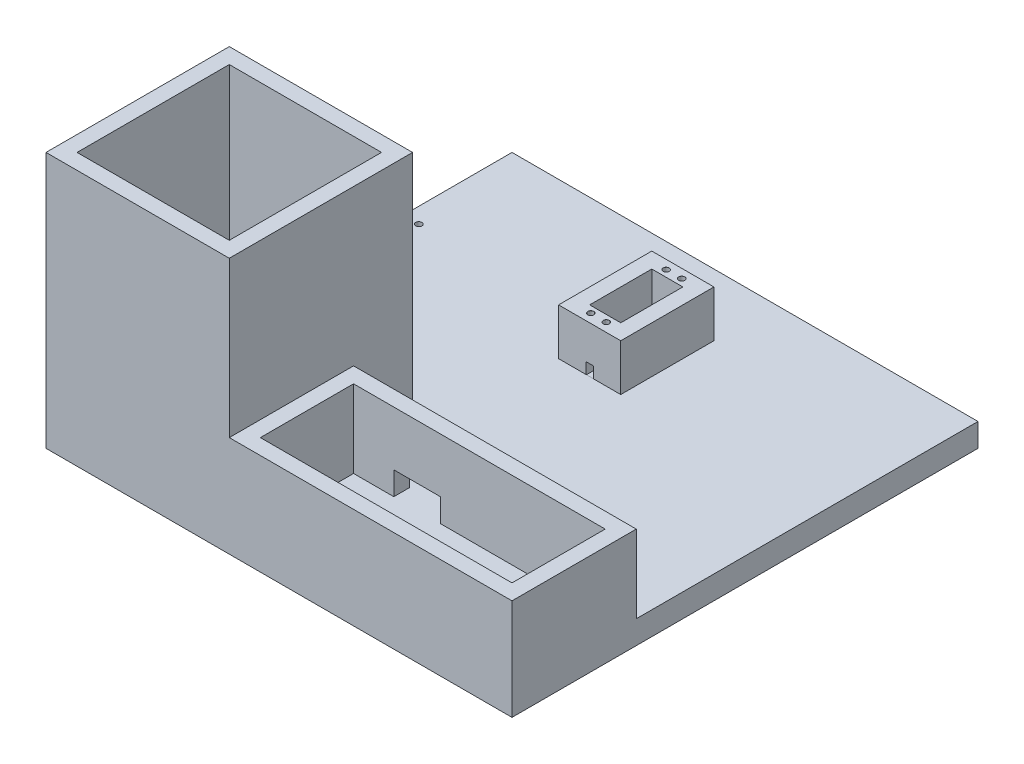
from build123d import *

# Parameters (mm, degrees)
CROQUIS1_W                               = 300
CROQUIS1_H                               = 300
SALIENTE_EXTRUIR1_DEPTH                  = 15
CROQUIS2_W                               = 98
CROQUIS2_H                               = 98
SALIENTE_EXTRUIR2_DEPTH                  = 150
CROQUIS3_W                               = 40
CROQUIS3_H                               = 60
CROQUIS3_W_2                             = 20
CROQUIS3_H_2                             = 40
SALIENTE_EXTRUIR3_DEPTH                  = 30
CROQUIS4_W                               = 182
CROQUIS4_H                               = 80
CROQUIS4_W_2                             = 162
CROQUIS4_H_2                             = 60
SALIENTE_EXTRUIR4_DEPTH                  = 50
TALADRO_DE_MARGEN_PARA_M3_51_D           = 3.9
TALADRO_DE_MARGEN_PARA_M3_51_DEPTH       = 15
TALADRO_DE_MARGEN_PARA_M3_51_CSINK_D     = 3.95
TALADRO_DE_MARGEN_PARA_M3_51_CSINK_ANGLE = 90
TALADRO_DE_MARGEN_PARA_M3_51_TIP         = 1.171678207
CROQUIS7_W                               = 5
CROQUIS7_H                               = 7.608570781
CORTAR_EXTRUIR1_DEPTH                    = 10
CROQUIS8_W                               = 30
CROQUIS8_H                               = 15
CORTAR_EXTRUIR2_DEPTH                    = 10
CROQUIS9_R                               = 2
CORTAR_EXTRUIR3_DEPTH                    = 20


with BuildPart() as part:
    # Croquis1 → Saliente-Extruir1 (new body)
    with BuildSketch(Plane(origin=(0, 0, 0), x_dir=(1, 0, 0), z_dir=(0, 1, 0))):
        Rectangle(CROQUIS1_W, CROQUIS1_H)
    extrude(amount=SALIENTE_EXTRUIR1_DEPTH)

    # Croquis2 → Saliente-Extruir2 (add)
    with BuildSketch(Plane(origin=(0, 15, 0), x_dir=(1, 0, 0), z_dir=(0, 1, 0))):
        Polygon((-150, -140), (-150, -150), (-32, -150), (-32, -55), (-32, -32), (-150, -32), (-150, -55), align=None)
        with Locations((-91, -91)):
            Rectangle(CROQUIS2_W, CROQUIS2_H, mode=Mode.SUBTRACT)
    extrude(amount=SALIENTE_EXTRUIR2_DEPTH)

    # Croquis3 → Saliente-Extruir3 (add)
    with BuildSketch(Plane(origin=(0, 15, 0), x_dir=(1, 0, 0), z_dir=(0, 1, 0))):
        with Locations((0, 80)):
            Rectangle(CROQUIS3_W, CROQUIS3_H)
        with Locations((0, 80)):
            Rectangle(CROQUIS3_W_2, CROQUIS3_H_2, mode=Mode.SUBTRACT)
    extrude(amount=SALIENTE_EXTRUIR3_DEPTH)

    # Croquis4 → Saliente-Extruir4 (add)
    with BuildSketch(Plane(origin=(0, 15, 0), x_dir=(1, 0, 0), z_dir=(0, 1, 0))):
        with Locations((59, -110)):
            Rectangle(CROQUIS4_W, CROQUIS4_H)
        with Locations((59, -110)):
            Rectangle(CROQUIS4_W_2, CROQUIS4_H_2, mode=Mode.SUBTRACT)
    extrude(amount=SALIENTE_EXTRUIR4_DEPTH)

    # Taladro de margen para M3.51
    with Locations(Plane(origin=(0, 45, 0), x_dir=(1, 0, 0), z_dir=(0, 1, 0))):
        with Locations((-5, 104.25), (5, 104.25), (-5, 55.75), (5, 55.75)):
            CounterSinkHole(TALADRO_DE_MARGEN_PARA_M3_51_D / 2, TALADRO_DE_MARGEN_PARA_M3_51_CSINK_D / 2, depth=TALADRO_DE_MARGEN_PARA_M3_51_DEPTH, counter_sink_angle=TALADRO_DE_MARGEN_PARA_M3_51_CSINK_ANGLE)
            with Locations((0, 0, -(TALADRO_DE_MARGEN_PARA_M3_51_DEPTH + TALADRO_DE_MARGEN_PARA_M3_51_TIP / 2))):  # 118° drill point
                Cone(0, TALADRO_DE_MARGEN_PARA_M3_51_D / 2, TALADRO_DE_MARGEN_PARA_M3_51_TIP, mode=Mode.SUBTRACT)

    # Croquis7 → Cortar-Extruir1 (cut)
    with BuildSketch(Plane.XY.offset(-50)):
        with Locations((0, 18.373101355)):
            Rectangle(CROQUIS7_W, CROQUIS7_H)
    extrude(amount=-CORTAR_EXTRUIR1_DEPTH, mode=Mode.SUBTRACT)

    # Croquis8 → Cortar-Extruir2 (cut)
    with BuildSketch(Plane.XY.offset(80)):
        with Locations((18.908102742, 22.5)):
            Rectangle(CROQUIS8_W, CROQUIS8_H)
    extrude(amount=-CORTAR_EXTRUIR2_DEPTH, mode=Mode.SUBTRACT)

    # Croquis9 → Cortar-Extruir3 (cut)
    with BuildSketch(Plane(origin=(0, 15, 0), x_dir=(1, 0, 0), z_dir=(0, 1, 0))):
        with Locations((-140, 80)):
            Circle(CROQUIS9_R)
    extrude(amount=-CORTAR_EXTRUIR3_DEPTH, mode=Mode.SUBTRACT)


solid = part.part
